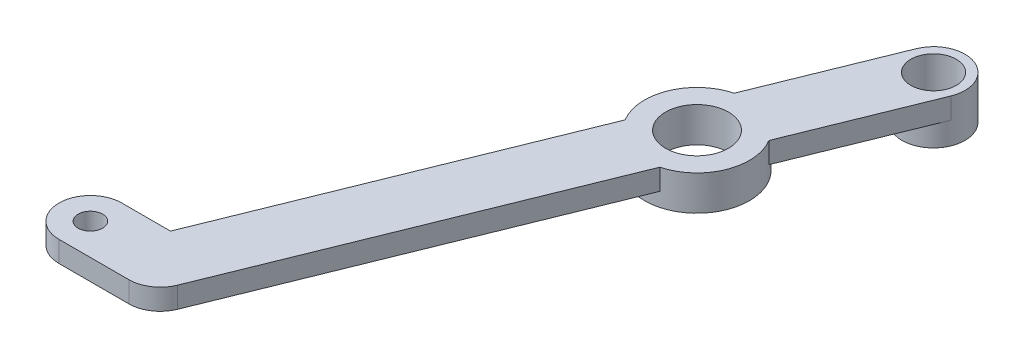
from build123d import *

# Parameters (mm, degrees)
SKETCH1_R                = 1.75
BOSS_EXTRUDE1_DEPTH      = 3
BOSS_EXTRUDE2_DEPTH      = 3
SKETCH3_R                = 4.5
SKETCH3_R_2              = 3.25
BOSS_EXTRUDE3_DEPTH      = 6.2
SKETCH4_R                = 3.25
CUT_EXTRUDE1_DEPTH       = 3
SKETCH5_R                = 7.5
BOSS_EXTRUDE4_DEPTH      = 2
BOSS_EXTRUDE4_DEPTH_BACK = 3
SKETCH6_R                = 4.5
CUT_EXTRUDE2_DEPTH       = 6


with BuildPart() as part:
    # Sketch1 → Boss-Extrude1 (new body)
    with BuildSketch(Plane(origin=(0, 0, 0), x_dir=(1, 0, 0), z_dir=(0, 1, 0))):
        with BuildLine():
            Line((0, -4.5), (10, -4.5))
            ThreePointArc((10, -4.5), (14.5, 0), (10, 4.5))
            Line((10, 4.5), (0, 4.5))
            ThreePointArc((0, 4.5), (-4.5, 0), (0, -4.5))
        make_face()
        Circle(SKETCH1_R, mode=Mode.SUBTRACT)
    extrude(amount=BOSS_EXTRUDE1_DEPTH)

    # Sketch2 → Boss-Extrude2 (add)
    with BuildSketch(Plane(origin=(0, 3, 0), x_dir=(1, 0, 0), z_dir=(0, 1, 0))):
        with BuildLine():
            Line((10, 0), (11.688465713, 4.171220869))
            ThreePointArc((11.688465713, 4.171220869), (10.860088975, 4.41704052), (10, 4.5))
            Line((10, 4.5), (6.96685822, 4.5))
            ThreePointArc((6.96685822, 4.5), (8.346615874, -1.181489024), (14.171220869, -1.688465713))
            Line((14.171220869, -1.688465713), (10, 0))
        make_face()
        with BuildLine():
            ThreePointArc((46.064462111, 77.10126181), (43.648814249, 74.646303405), (40.204775529, 74.618506654))
            Line((40.204775529, 74.618506654), (11.688465713, 4.171220869))
            ThreePointArc((11.688465713, 4.171220869), (14.143424118, 1.755573007), (14.171220869, -1.688465713))
            Line((14.171220869, -1.688465713), (46.064462111, 77.10126181))
        make_face()
        with BuildLine():
            ThreePointArc((14.171220869, -1.688465713), (14.143424118, 1.755573007), (11.688465713, 4.171220869))
            Line((11.688465713, 4.171220869), (10, 0))
            Line((10, 0), (14.171220869, -1.688465713))
        make_face()
        with BuildLine():
            Line((11.688465713, 4.171220869), (40.204775529, 74.618506654))
            ThreePointArc((40.204775529, 74.618506654), (37.749817124, 77.034154516), (37.722020373, 80.478193235))
            Line((37.722020373, 80.478193235), (6.96685822, 4.5))
            Line((6.96685822, 4.5), (10, 4.5))
            ThreePointArc((10, 4.5), (10.860088975, 4.41704052), (11.688465713, 4.171220869))
        make_face()
        with BuildLine():
            Line((37.722020373, 80.478193235), (41.893241242, 78.789727523))
            Line((41.893241242, 78.789727523), (46.064462111, 77.10126181))
            ThreePointArc((46.064462111, 77.10126181), (46.310281762, 77.929638548), (46.393241242, 78.789727523))
            ThreePointArc((46.393241242, 78.789727523), (42.753330217, 83.206768043), (37.722020373, 80.478193235))
        make_face()
        with BuildLine():
            Line((46.064462111, 77.10126181), (41.893241242, 78.789727523))
            Line((41.893241242, 78.789727523), (40.204775529, 74.618506654))
            ThreePointArc((40.204775529, 74.618506654), (43.648814249, 74.646303405), (46.064462111, 77.10126181))
        make_face()
        with BuildLine():
            Line((40.204775529, 74.618506654), (41.893241242, 78.789727523))
            Line((41.893241242, 78.789727523), (37.722020373, 80.478193235))
            ThreePointArc((37.722020373, 80.478193235), (37.749817124, 77.034154516), (40.204775529, 74.618506654))
        make_face()
    extrude(amount=-BOSS_EXTRUDE2_DEPTH)

    # Sketch3 → Boss-Extrude3 (add)
    with BuildSketch(Plane(origin=(0, 3, 0), x_dir=(1, 0, 0), z_dir=(0, 1, 0))):
        with Locations((41.893241242, 78.789727523)):
            Circle(SKETCH3_R)
        with Locations((41.893241242, 78.789727523)):
            Circle(SKETCH3_R_2, mode=Mode.SUBTRACT)
    extrude(amount=-BOSS_EXTRUDE3_DEPTH)

    # Sketch4 → Cut-Extrude1 (cut)
    with BuildSketch(Plane(origin=(0, 3, 0), x_dir=(1, 0, 0), z_dir=(0, 1, 0))):
        with Locations((41.893241242, 78.789727523)):
            Circle(SKETCH4_R)
    extrude(amount=-CUT_EXTRUDE1_DEPTH, mode=Mode.SUBTRACT)

    # Sketch5 → Boss-Extrude4 (add, two sides)
    with BuildSketch(Plane.XZ) as boss_extrude4_sk:
        with Locations((32.137661568, -54.68934028)):
            Circle(SKETCH5_R)
    extrude(amount=BOSS_EXTRUDE4_DEPTH)
    extrude(boss_extrude4_sk.sketch, amount=-BOSS_EXTRUDE4_DEPTH_BACK)

    # Sketch6 → Cut-Extrude2 (cut, through all)
    with BuildSketch(Plane.XZ.offset(2)):
        with Locations((32.137661568, -54.68934028)):
            Circle(SKETCH6_R)
    extrude(amount=-CUT_EXTRUDE2_DEPTH, mode=Mode.SUBTRACT)


solid = part.part
